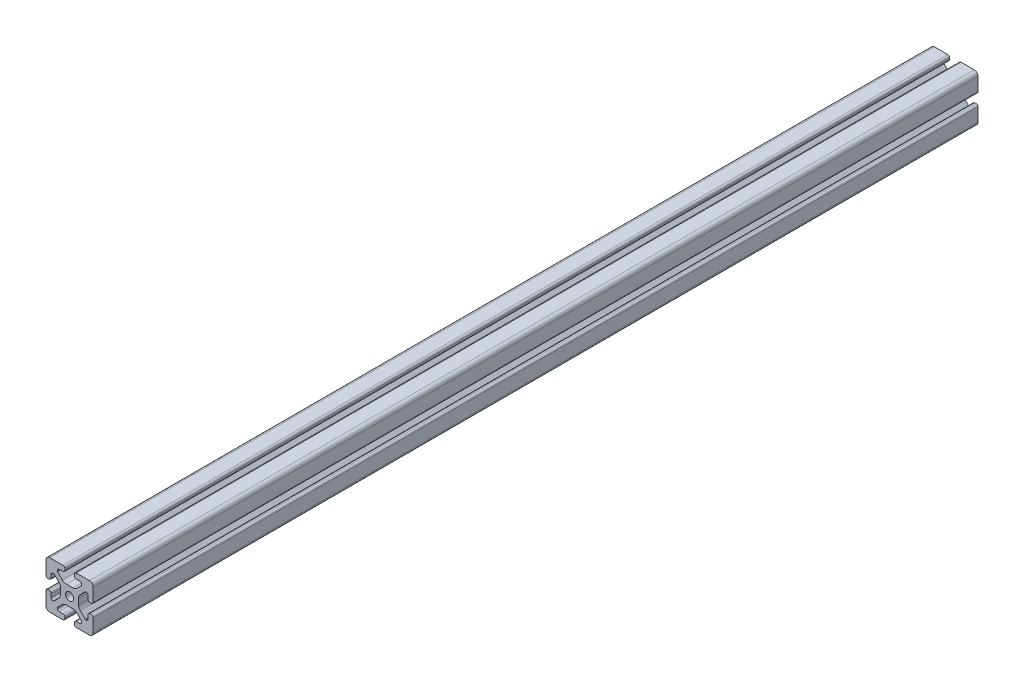
from build123d import *

# Parameters (mm, degrees)
SKETCH1_R           = 3.4
BOSS_EXTRUDE1_DEPTH = 750


with BuildPart() as part:
    # Sketch1 → Boss-Extrude1 (new body)
    with BuildSketch(Plane.XY):
        with BuildLine():
            Line((-8.715, -15.524615034), (-5.63, -15.524615034))
            ThreePointArc((-5.63, -15.524615034), (-4.519842354, -15.984457388), (-4.06, -17.094615034))
            Line((-4.06, -17.094615034), (-4.06, -18.43))
            ThreePointArc((-4.06, -18.43), (-4.519842354, -19.540157646), (-5.63, -20))
            Line((-5.63, -20), (-16.674615034, -20))
            ThreePointArc((-16.674615034, -20), (-18.951578385, -19.194274381), (-20, -17.018368134))
            Line((-20, -17.018368134), (-20, -5.757918808))
            ThreePointArc((-20, -5.757918808), (-19.564709668, -4.603883664), (-18.43, -4.120449326))
            Line((-18.43, -4.120449326), (-17.248545805, -4.120449326))
            ThreePointArc((-17.248545805, -4.120449326), (-16.114784845, -4.604407881), (-15.67999625, -5.757919334))
            Line((-15.67999625, -5.757919334), (-15.67999625, -8.715399492))
            ThreePointArc((-15.67999625, -8.715399492), (-15.220153896, -9.825557139), (-14.10999625, -10.285399492))
            Line((-14.10999625, -10.285399492), (-13.816903094, -10.285399492))
            ThreePointArc((-13.816903094, -10.285399492), (-13.526063686, -10.227547937), (-13.279501941, -10.062800646))
            Line((-13.279501941, -10.062800646), (-9.076242789, -5.859541495))
            ThreePointArc((-9.076242789, -5.859541495), (-8.046572221, -4.318530588), (-7.685, -2.500784284))
            Line((-7.685, -2.500784284), (-7.685, 2.500784284))
            ThreePointArc((-7.685, 2.500784284), (-8.046572221, 4.318530588), (-9.076242789, 5.859541495))
            Line((-9.076242789, 5.859541495), (-13.040489136, 9.823787841))
            ThreePointArc((-13.040489136, 9.823787841), (-13.354224618, 10.012729352), (-13.71989919, 10.033001362))
            Line((-13.71989919, 10.033001362), (-14.05520779, 10.044710596))
            ThreePointArc((-14.05520779, 10.044710596), (-15.200613642, 9.605030484), (-15.68, 8.475666998))
            Line((-15.68, 8.475666998), (-15.68, 5.572979049))
            ThreePointArc((-15.68, 5.572979049), (-16.139842354, 4.462821403), (-17.25, 4.002979049))
            Line((-17.25, 4.002979049), (-18.43, 4.002979049))
            ThreePointArc((-18.43, 4.002979049), (-19.540157646, 4.462821403), (-20, 5.572979049))
            Line((-20, 5.572979049), (-20, 13.004526564))
            Line((-20, 13.004526564), (-20, 16.83))
            ThreePointArc((-20, 16.83), (-19.071528496, 19.071528496), (-16.83, 20))
            Line((-16.83, 20), (-5.63, 20))
            ThreePointArc((-5.63, 20), (-4.519842354, 19.540157646), (-4.06, 18.43))
            Line((-4.06, 18.43), (-4.06, 17.094615034))
            ThreePointArc((-4.06, 17.094615034), (-4.519842354, 15.984457388), (-5.63, 15.524615034))
            Line((-5.63, 15.524615034), (-8.715, 15.524615034))
            ThreePointArc((-8.715, 15.524615034), (-9.825157646, 15.06477268), (-10.285, 13.954615034))
            Line((-10.285, 13.954615034), (-10.285, 13.492503602))
            ThreePointArc((-10.285, 13.492503602), (-10.227148445, 13.201664194), (-10.062401154, 12.955102448))
            Line((-10.062401154, 12.955102448), (-6.217092793, 9.109794088))
            ThreePointArc((-6.217092793, 9.109794088), (-4.63891877, 8.055291919), (-2.777335583, 7.685))
            Line((-2.777335583, 7.685), (2.777335583, 7.685))
            ThreePointArc((2.777335583, 7.685), (4.63891877, 8.055291919), (6.217092793, 9.109794088))
            Line((6.217092793, 9.109794088), (10.062401154, 12.955102448))
            ThreePointArc((10.062401154, 12.955102448), (10.227148445, 13.201664194), (10.285, 13.492503602))
            Line((10.285, 13.492503602), (10.285, 13.954615034))
            ThreePointArc((10.285, 13.954615034), (9.825157646, 15.06477268), (8.715, 15.524615034))
            Line((8.715, 15.524615034), (5.63, 15.524615034))
            ThreePointArc((5.63, 15.524615034), (4.519842354, 15.984457388), (4.06, 17.094615034))
            Line((4.06, 17.094615034), (4.06, 18.43))
            ThreePointArc((4.06, 18.43), (4.519842354, 19.540157646), (5.63, 20))
            Line((5.63, 20), (12.979635074, 20))
            Line((12.979635074, 20), (16.83, 20))
            ThreePointArc((16.83, 20), (19.071528496, 19.071528496), (20, 16.83))
            Line((20, 16.83), (20, 13.001098436))
            Line((20, 13.001098436), (20, 5.630000526))
            ThreePointArc((20, 5.630000526), (19.540157646, 4.519842879), (18.43, 4.060000526))
            Line((18.43, 4.060000526), (17.24999625, 4.060000526))
            ThreePointArc((17.24999625, 4.060000526), (16.139838603, 4.519842879), (15.67999625, 5.630000526))
            Line((15.67999625, 5.630000526), (15.67999625, 8.715399492))
            ThreePointArc((15.67999625, 8.715399492), (15.220153896, 9.825557139), (14.10999625, 10.285399492))
            Line((14.10999625, 10.285399492), (13.816903094, 10.285399492))
            ThreePointArc((13.816903094, 10.285399492), (13.526063686, 10.227547937), (13.279501941, 10.062800646))
            Line((13.279501941, 10.062800646), (9.076242789, 5.859541495))
            ThreePointArc((9.076242789, 5.859541495), (8.046572221, 4.318530588), (7.685, 2.500784284))
            Line((7.685, 2.500784284), (7.685, -2.500784284))
            ThreePointArc((7.685, -2.500784284), (8.046572221, -4.318530588), (9.076242789, -5.859541495))
            Line((9.076242789, -5.859541495), (13.163657296, -9.946956002))
            ThreePointArc((13.163657296, -9.946956002), (13.35903797, -10.160433474), (13.6200547, -10.285399492))
            Line((13.6200547, -10.285399492), (14.10999625, -10.285399492))
            ThreePointArc((14.10999625, -10.285399492), (15.220153896, -9.825557139), (15.67999625, -8.715399492))
            Line((15.67999625, -8.715399492), (15.67999625, -5.630000526))
            ThreePointArc((15.67999625, -5.630000526), (16.139838603, -4.519842879), (17.24999625, -4.060000526))
            Line((17.24999625, -4.060000526), (18.43, -4.060000526))
            ThreePointArc((18.43, -4.060000526), (19.540157646, -4.519842879), (20, -5.630000526))
            Line((20, -5.630000526), (20, -16.83))
            ThreePointArc((20, -16.83), (19.071528496, -19.071528496), (16.83, -20))
            Line((16.83, -20), (13, -20))
            Line((13, -20), (5.63, -20))
            ThreePointArc((5.63, -20), (4.519842354, -19.540157646), (4.06, -18.43))
            Line((4.06, -18.43), (4.06, -17.094615034))
            ThreePointArc((4.06, -17.094615034), (4.519842354, -15.984457388), (5.63, -15.524615034))
            Line((5.63, -15.524615034), (8.715, -15.524615034))
            ThreePointArc((8.715, -15.524615034), (9.825157646, -15.06477268), (10.285, -13.954615034))
            Line((10.285, -13.954615034), (10.285, -13.492503602))
            ThreePointArc((10.285, -13.492503602), (10.227148445, -13.201664194), (10.062401154, -12.955102448))
            Line((10.062401154, -12.955102448), (6.217092793, -9.109794088))
            ThreePointArc((6.217092793, -9.109794088), (4.63891877, -8.055291919), (2.777335583, -7.685))
            Line((2.777335583, -7.685), (-2.777335583, -7.685))
            ThreePointArc((-2.777335583, -7.685), (-4.63891877, -8.055291919), (-6.217092793, -9.109794088))
            Line((-6.217092793, -9.109794088), (-10.062401154, -12.955102448))
            ThreePointArc((-10.062401154, -12.955102448), (-10.227148445, -13.201664194), (-10.285, -13.492503602))
            Line((-10.285, -13.492503602), (-10.285, -13.954615034))
            ThreePointArc((-10.285, -13.954615034), (-9.825157646, -15.06477268), (-8.715, -15.524615034))
        make_face()
        Circle(SKETCH1_R, mode=Mode.SUBTRACT)
    extrude(amount=BOSS_EXTRUDE1_DEPTH)


solid = part.part
